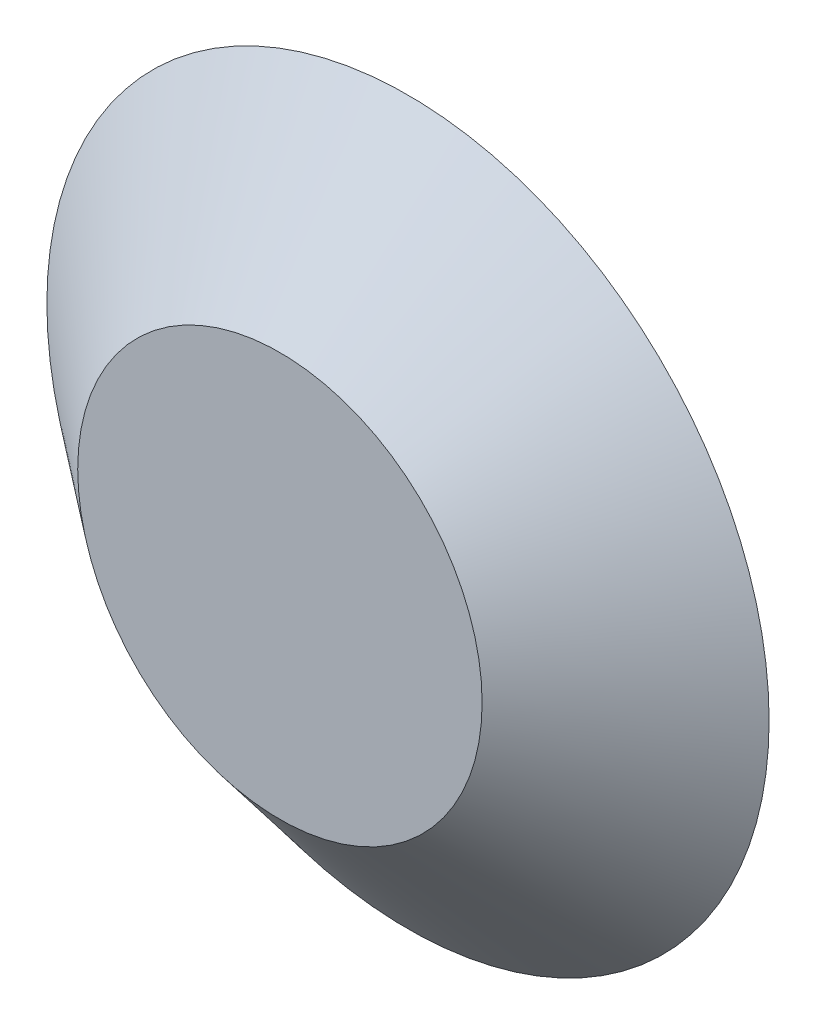
from build123d import *

# Parameters (mm, degrees)
SKETCH1_R           = 128
BOSS_EXTRUDE1_DEPTH = 45.4
BOSS_EXTRUDE1_TAPER = 51.13


with BuildPart() as part:
    # Sketch1 → Boss-Extrude1 (new body)
    with BuildSketch(Plane.XY):
        Circle(SKETCH1_R)
    extrude(amount=BOSS_EXTRUDE1_DEPTH, taper=BOSS_EXTRUDE1_TAPER)


solid = part.part
